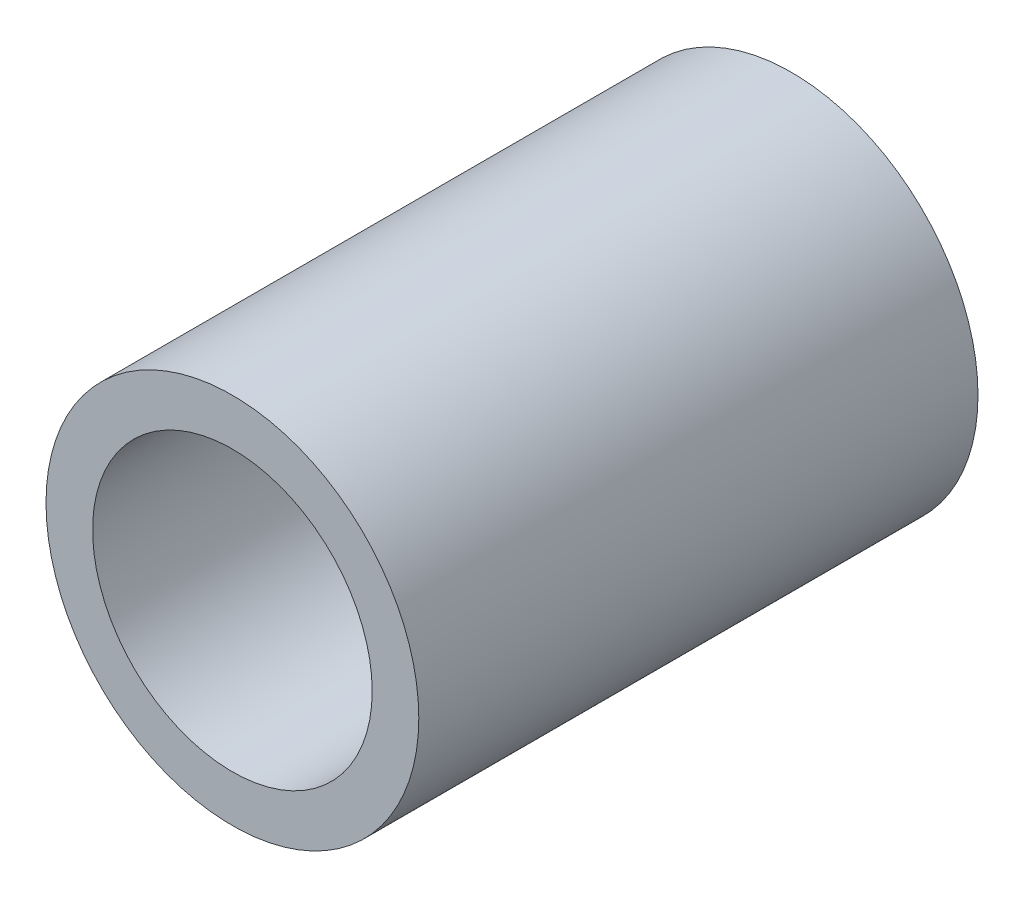
from build123d import *

# Parameters (mm, degrees)
SKETCH1_R           = 25.4
SKETCH1_R_2         = 19.05
BOSS_EXTRUDE1_DEPTH = 76.2


with BuildPart() as part:
    # Sketch1 → Boss-Extrude1 (new body)
    with BuildSketch(Plane.XY):
        Circle(SKETCH1_R)
        Circle(SKETCH1_R_2, mode=Mode.SUBTRACT)
    extrude(amount=BOSS_EXTRUDE1_DEPTH)


solid = part.part
